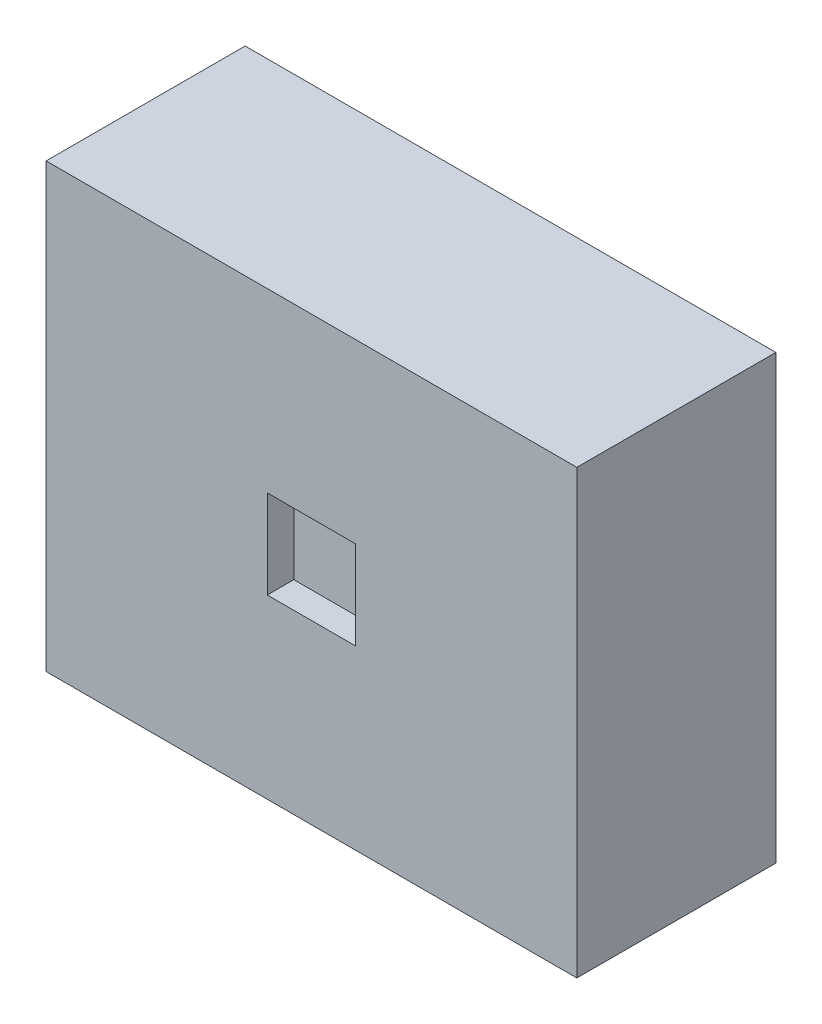
from build123d import *

# Parameters (mm, degrees)
SKETCH1_W           = 120
SKETCH1_H           = 45
BOSS_EXTRUDE1_DEPTH = 100
SKETCH3_W           = 20
SKETCH3_H           = 20
CUT_EXTRUDE2_DEPTH  = 6


with BuildPart() as part:
    # Sketch1 → Boss-Extrude1 (new body)
    with BuildSketch(Plane(origin=(0, 0, 0), x_dir=(1, 0, 0), z_dir=(0, 1, 0))):
        Rectangle(SKETCH1_W, SKETCH1_H)
    extrude(amount=BOSS_EXTRUDE1_DEPTH)

    # Sketch3 → Cut-Extrude2 (cut)
    with BuildSketch(Plane.XY.offset(22.5)):
        with Locations((0, 50)):
            Rectangle(SKETCH3_W, SKETCH3_H)
    extrude(amount=-CUT_EXTRUDE2_DEPTH, mode=Mode.SUBTRACT)


solid = part.part
